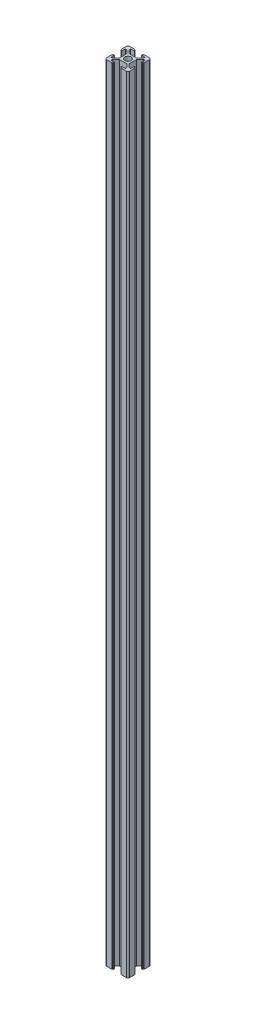
from build123d import *

# Parameters (mm, degrees)
SKETCH1_R           = 2.75
BOSS_EXTRUDE1_DEPTH = 680.25


with BuildPart() as part:
    # Sketch1 → Boss-Extrude1 (new body)
    with BuildSketch(Plane.XZ):
        with BuildLine():
            Line((-8.5, -10), (-3.75, -10))
            Line((-3.75, -10), (-3.75, -9.65))
            ThreePointArc((-3.75, -9.65), (-3.632842712, -9.367157288), (-3.35, -9.25))
            Line((-3.35, -9.25), (-3, -9.25))
            Line((-3, -9.25), (-3, -8.5))
            Line((-3, -8.5), (-6.2, -8.5))
            Line((-6.2, -8.5), (-6.2, -7.260660172))
            Line((-6.2, -7.260660172), (-3.239339828, -4.3))
            Line((-3.239339828, -4.3), (3.239339828, -4.3))
            Line((3.239339828, -4.3), (6.2, -7.260660172))
            Line((6.2, -7.260660172), (6.2, -8.5))
            Line((6.2, -8.5), (3, -8.5))
            Line((3, -8.5), (3, -9.25))
            Line((3, -9.25), (3.35, -9.25))
            ThreePointArc((3.35, -9.25), (3.632842712, -9.367157288), (3.75, -9.65))
            Line((3.75, -9.65), (3.75, -10))
            Line((3.75, -10), (8.5, -10))
            ThreePointArc((8.5, -10), (9.560660172, -9.560660172), (10, -8.5))
            Line((10, -8.5), (10, -3.75))
            Line((10, -3.75), (9.65, -3.75))
            ThreePointArc((9.65, -3.75), (9.367157288, -3.632842712), (9.25, -3.35))
            Line((9.25, -3.35), (9.25, -3))
            Line((9.25, -3), (8.5, -3))
            Line((8.5, -3), (8.5, -6.2))
            Line((8.5, -6.2), (7.260660172, -6.2))
            Line((7.260660172, -6.2), (4.3, -3.239339828))
            Line((4.3, -3.239339828), (4.3, 3.239339828))
            Line((4.3, 3.239339828), (7.260660172, 6.2))
            Line((7.260660172, 6.2), (8.5, 6.2))
            Line((8.5, 6.2), (8.5, 3))
            Line((8.5, 3), (9.25, 3))
            Line((9.25, 3), (9.25, 3.35))
            ThreePointArc((9.25, 3.35), (9.367157288, 3.632842712), (9.65, 3.75))
            Line((9.65, 3.75), (10, 3.75))
            Line((10, 3.75), (10, 8.5))
            ThreePointArc((10, 8.5), (9.560660172, 9.560660172), (8.5, 10))
            Line((8.5, 10), (3.75, 10))
            Line((3.75, 10), (3.75, 9.65))
            ThreePointArc((3.75, 9.65), (3.632842712, 9.367157288), (3.35, 9.25))
            Line((3.35, 9.25), (3, 9.25))
            Line((3, 9.25), (3, 8.5))
            Line((3, 8.5), (6.2, 8.5))
            Line((6.2, 8.5), (6.2, 7.260660172))
            Line((6.2, 7.260660172), (3.239339828, 4.3))
            Line((3.239339828, 4.3), (-3.239339828, 4.3))
            Line((-3.239339828, 4.3), (-6.2, 7.260660172))
            Line((-6.2, 7.260660172), (-6.2, 8.5))
            Line((-6.2, 8.5), (-3, 8.5))
            Line((-3, 8.5), (-3, 9.25))
            Line((-3, 9.25), (-3.35, 9.25))
            ThreePointArc((-3.35, 9.25), (-3.632842712, 9.367157288), (-3.75, 9.65))
            Line((-3.75, 9.65), (-3.75, 10))
            Line((-3.75, 10), (-8.5, 10))
            ThreePointArc((-8.5, 10), (-9.560660172, 9.560660172), (-10, 8.5))
            Line((-10, 8.5), (-10, 3.75))
            Line((-10, 3.75), (-9.65, 3.75))
            ThreePointArc((-9.65, 3.75), (-9.367157288, 3.632842712), (-9.25, 3.35))
            Line((-9.25, 3.35), (-9.25, 3))
            Line((-9.25, 3), (-8.5, 3))
            Line((-8.5, 3), (-8.5, 6.2))
            Line((-8.5, 6.2), (-7.260660172, 6.2))
            Line((-7.260660172, 6.2), (-4.3, 3.239339828))
            Line((-4.3, 3.239339828), (-4.3, -3.239339828))
            Line((-4.3, -3.239339828), (-7.260660172, -6.2))
            Line((-7.260660172, -6.2), (-8.5, -6.2))
            Line((-8.5, -6.2), (-8.5, -3))
            Line((-8.5, -3), (-9.25, -3))
            Line((-9.25, -3), (-9.25, -3.35))
            ThreePointArc((-9.25, -3.35), (-9.367157288, -3.632842712), (-9.65, -3.75))
            Line((-9.65, -3.75), (-10, -3.75))
            Line((-10, -3.75), (-10, -8.5))
            ThreePointArc((-10, -8.5), (-9.560660172, -9.560660172), (-8.5, -10))
        make_face()
        Circle(SKETCH1_R, mode=Mode.SUBTRACT)
    extrude(amount=-BOSS_EXTRUDE1_DEPTH)


solid = part.part
